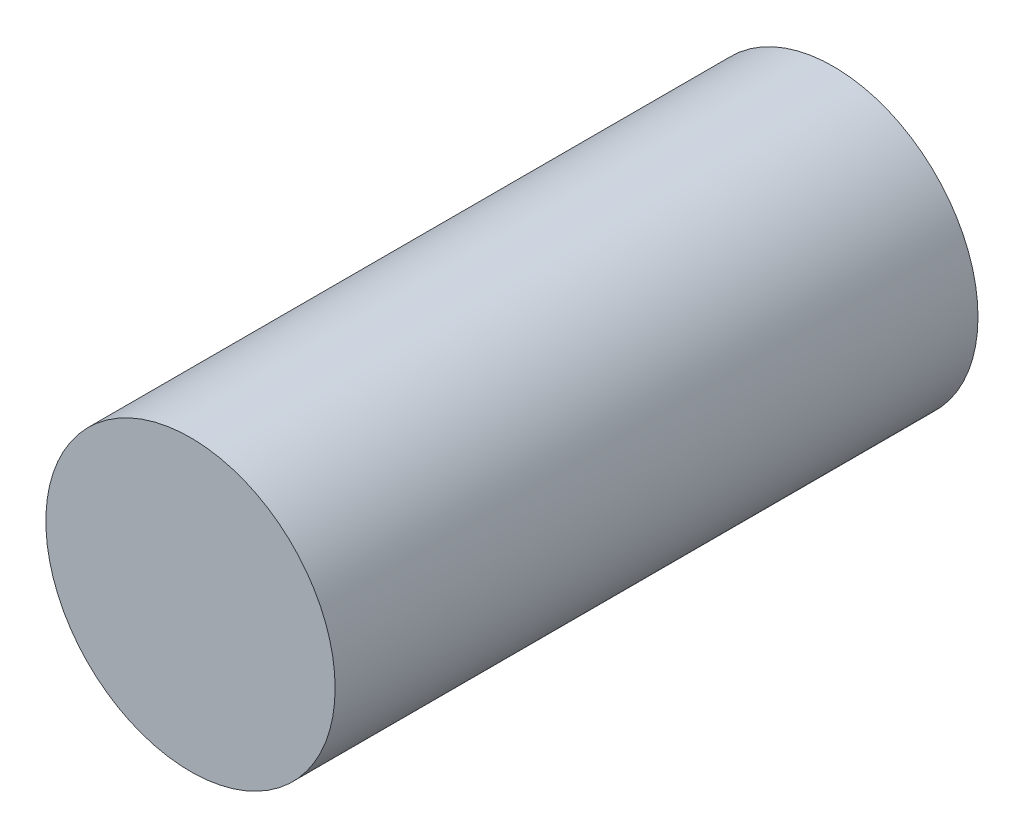
from build123d import *

# Parameters (mm, degrees)
SKETCH1_R           = 4.5
BOSS_EXTRUDE1_DEPTH = 20


with BuildPart() as part:
    # Sketch1 → Boss-Extrude1 (new body)
    with BuildSketch(Plane.XY):
        Circle(SKETCH1_R)
    extrude(amount=BOSS_EXTRUDE1_DEPTH)


solid = part.part
